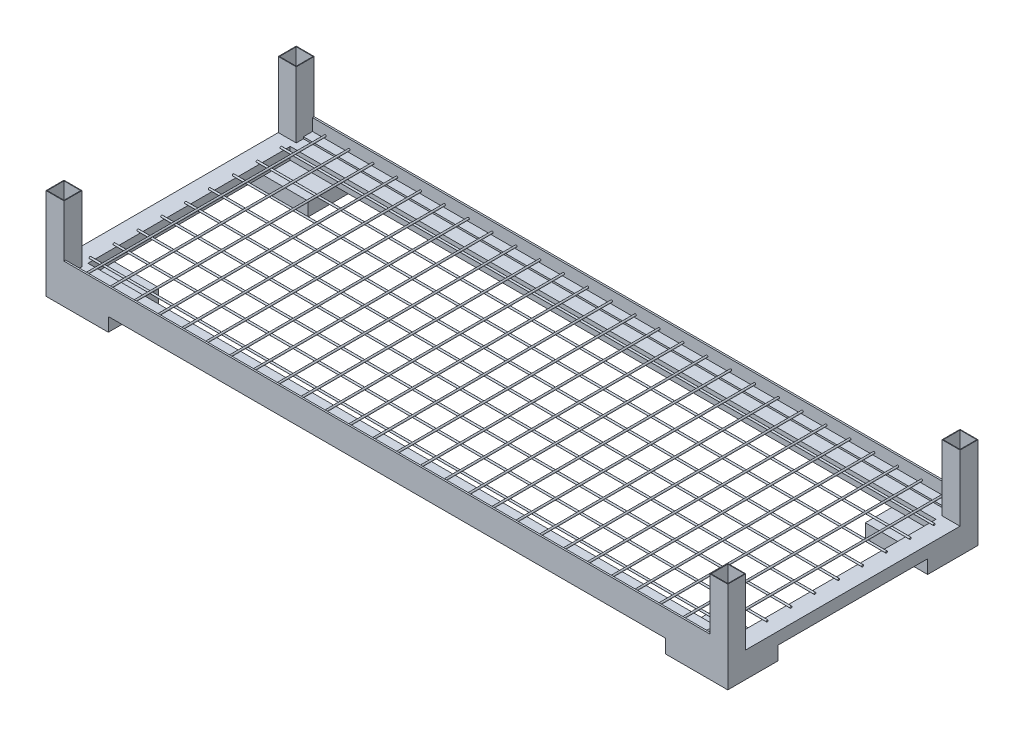
from build123d import *

# Parameters (mm, degrees)
SKETCH1_W             = 1444.625
SKETCH1_H             = 530.225
SKETCH1_W_2           = 1368.425
SKETCH1_H_2           = 428.625
BOSS_EXTRUDE1_DEPTH   = 25.4
SKETCH2_W             = 38.1
SKETCH2_H             = 38.1
SKETCH2_W_2           = 35.56
SKETCH2_H_2           = 35.56
BOSS_EXTRUDE2_DEPTH   = 139.7
SKETCH3_W             = 1368.425
SKETCH3_H             = 22.86
BOSS_EXTRUDE3_DEPTH   = 3.81
SKETCH4_R             = 1.905
BOSS_EXTRUDE4_DEPTH   = 1384.3
BOSS_EXTRUDE4_2_DEPTH = 1384.3
BOSS_EXTRUDE4_3_DEPTH = 1384.3
BOSS_EXTRUDE4_4_DEPTH = 1384.3
BOSS_EXTRUDE4_5_DEPTH = 1384.3
BOSS_EXTRUDE4_6_DEPTH = 1384.3
BOSS_EXTRUDE4_7_DEPTH = 1384.3
BOSS_EXTRUDE4_8_DEPTH = 1384.3
BOSS_EXTRUDE4_9_DEPTH = 1384.3
SKETCH5_W             = 1368.425
SKETCH5_H             = 3.556
BOSS_EXTRUDE5_DEPTH   = 25.4
SKETCH6_R             = 1.905
BOSS_EXTRUDE6_DEPTH   = 523.113
SKETCH7_W             = 132.08
SKETCH7_H             = 106.68
BOSS_EXTRUDE7_DEPTH   = 3.556
SKETCH8_W             = 132.08
SKETCH8_H             = 106.68
SKETCH8_W_2           = 124.968
SKETCH8_H_2           = 99.568
BOSS_EXTRUDE8_DEPTH   = 25.4
SKETCH9_W             = 35.56
SKETCH9_H             = 35.56
CUT_EXTRUDE1_DEPTH    = 22.606


with BuildPart() as part:
    # Sketch1 → Boss-Extrude1 (new body)
    with BuildSketch(Plane(origin=(0, 0, 0), x_dir=(1, 0, 0), z_dir=(0, 1, 0))):
        Rectangle(SKETCH1_W, SKETCH1_H)
        Rectangle(SKETCH1_W_2, SKETCH1_H_2, mode=Mode.SUBTRACT)
    extrude(amount=BOSS_EXTRUDE1_DEPTH)

    # Sketch2 → Boss-Extrude2 (add)
    with BuildSketch(Plane(origin=(0, 25.4, 0), x_dir=(1, 0, 0), z_dir=(0, 1, 0))):
        with Locations((-703.2625, 246.0625)):
            Rectangle(SKETCH2_W, SKETCH2_H)
        with Locations((-703.2625, 246.0625)):
            Rectangle(SKETCH2_W_2, SKETCH2_H_2, mode=Mode.SUBTRACT)
        with Locations((-703.2625, -246.0625)):
            Rectangle(SKETCH2_W, SKETCH2_H)
        with Locations((-703.2625, -246.0625)):
            Rectangle(SKETCH2_W_2, SKETCH2_H_2, mode=Mode.SUBTRACT)
        with Locations((703.2625, -246.0625)):
            Rectangle(SKETCH2_W, SKETCH2_H)
        with Locations((703.2625, -246.0625)):
            Rectangle(SKETCH2_W_2, SKETCH2_H_2, mode=Mode.SUBTRACT)
        with Locations((703.2625, 246.0625)):
            Rectangle(SKETCH2_W, SKETCH2_H)
        with Locations((703.2625, 246.0625)):
            Rectangle(SKETCH2_W_2, SKETCH2_H_2, mode=Mode.SUBTRACT)
    extrude(amount=BOSS_EXTRUDE2_DEPTH)

    # Sketch3 → Boss-Extrude3 (add)
    with BuildSketch(Plane(origin=(0, 25.4, 0), x_dir=(1, 0, 0), z_dir=(0, 1, 0))):
        with Locations((0, 253.6825)):
            Rectangle(SKETCH3_W, SKETCH3_H)
        with Locations((0, -253.6825)):
            Rectangle(SKETCH3_W, SKETCH3_H)
    extrude(amount=BOSS_EXTRUDE3_DEPTH)

    # Sketch5 → Boss-Extrude5 (add)
    with BuildSketch(Plane(origin=(0, 29.21, 0), x_dir=(1, 0, 0), z_dir=(0, 1, 0))):
        with Locations((0, -263.3345)):
            Rectangle(SKETCH5_W, SKETCH5_H)
        with Locations((0, 263.3345)):
            Rectangle(SKETCH5_W, SKETCH5_H)
    extrude(amount=BOSS_EXTRUDE5_DEPTH)

    # Sketch6 → Boss-Extrude6 (add)
    with BuildSketch(Plane(origin=(0, 0, 261.5565), x_dir=(-1, 0, 0), z_dir=(0, 0, -1))):
        with Locations((0, 34.925)):
            Circle(SKETCH6_R)
        with Locations((50.546, 34.925)):
            Circle(SKETCH6_R)
        with Locations((101.092, 34.925)):
            Circle(SKETCH6_R)
        with Locations((151.638, 34.925)):
            Circle(SKETCH6_R)
        with Locations((202.184, 34.925)):
            Circle(SKETCH6_R)
        with Locations((252.73, 34.925)):
            Circle(SKETCH6_R)
        with Locations((303.276, 34.925)):
            Circle(SKETCH6_R)
        with Locations((353.822, 34.925)):
            Circle(SKETCH6_R)
        with Locations((404.368, 34.925)):
            Circle(SKETCH6_R)
        with Locations((454.914, 34.925)):
            Circle(SKETCH6_R)
        with Locations((505.46, 34.925)):
            Circle(SKETCH6_R)
        with Locations((556.006, 34.925)):
            Circle(SKETCH6_R)
        with Locations((606.552, 34.925)):
            Circle(SKETCH6_R)
        with Locations((657.098, 34.925)):
            Circle(SKETCH6_R)
        with Locations((-50.546, 34.925)):
            Circle(SKETCH6_R)
        with Locations((-101.092, 34.925)):
            Circle(SKETCH6_R)
        with Locations((-151.638, 34.925)):
            Circle(SKETCH6_R)
        with Locations((-202.184, 34.925)):
            Circle(SKETCH6_R)
        with Locations((-252.73, 34.925)):
            Circle(SKETCH6_R)
        with Locations((-303.276, 34.925)):
            Circle(SKETCH6_R)
        with Locations((-353.822, 34.925)):
            Circle(SKETCH6_R)
        with Locations((-404.368, 34.925)):
            Circle(SKETCH6_R)
        with Locations((-454.914, 34.925)):
            Circle(SKETCH6_R)
        with Locations((-505.46, 34.925)):
            Circle(SKETCH6_R)
        with Locations((-556.006, 34.925)):
            Circle(SKETCH6_R)
        with Locations((-606.552, 34.925)):
            Circle(SKETCH6_R)
        with Locations((-657.098, 34.925)):
            Circle(SKETCH6_R)
    extrude(amount=BOSS_EXTRUDE6_DEPTH)

    # Sketch7 → Boss-Extrude7 (add)
    with BuildSketch(Plane.XZ):
        with Locations((-656.2725, -211.7725)):
            Rectangle(SKETCH7_W, SKETCH7_H)
        with Locations((-656.2725, 211.7725)):
            Rectangle(SKETCH7_W, SKETCH7_H)
        with Locations((656.2725, -211.7725)):
            Rectangle(SKETCH7_W, SKETCH7_H)
        with Locations((656.2725, 211.7725)):
            Rectangle(SKETCH7_W, SKETCH7_H)
    extrude(amount=BOSS_EXTRUDE7_DEPTH)

    # Sketch8 → Boss-Extrude8 (add)
    with BuildSketch(Plane.XZ.offset(3.556)):
        with Locations((-656.2725, -211.7725)):
            Rectangle(SKETCH8_W, SKETCH8_H)
        with Locations((-656.2725, -211.7725)):
            Rectangle(SKETCH8_W_2, SKETCH8_H_2, mode=Mode.SUBTRACT)
        with Locations((-656.2725, 211.7725)):
            Rectangle(SKETCH8_W, SKETCH8_H)
        with Locations((-656.2725, 211.7725)):
            Rectangle(SKETCH8_W_2, SKETCH8_H_2, mode=Mode.SUBTRACT)
        with Locations((656.2725, 211.7725)):
            Rectangle(SKETCH8_W, SKETCH8_H)
        with Locations((656.2725, 211.7725)):
            Rectangle(SKETCH8_W_2, SKETCH8_H_2, mode=Mode.SUBTRACT)
        with Locations((656.2725, -211.7725)):
            Rectangle(SKETCH8_W, SKETCH8_H)
        with Locations((656.2725, -211.7725)):
            Rectangle(SKETCH8_W_2, SKETCH8_H_2, mode=Mode.SUBTRACT)
    extrude(amount=BOSS_EXTRUDE8_DEPTH)

    # Sketch9 → Cut-Extrude1 (cut)
    with BuildSketch(Plane(origin=(0, 25.4, 0), x_dir=(1, 0, 0), z_dir=(0, 1, 0))):
        with Locations((-703.2625, 246.0625)):
            Rectangle(SKETCH9_W, SKETCH9_H)
        with Locations((-703.2625, -246.0625)):
            Rectangle(SKETCH9_W, SKETCH9_H)
        with Locations((703.2625, -246.0625)):
            Rectangle(SKETCH9_W, SKETCH9_H)
        with Locations((703.2625, 246.0625)):
            Rectangle(SKETCH9_W, SKETCH9_H)
    extrude(amount=-CUT_EXTRUDE1_DEPTH, mode=Mode.SUBTRACT)


with BuildPart() as body_2:
    # Sketch4 → Boss-Extrude4 (new body)
    with BuildSketch(Plane(origin=(-690.5625, 0, 0), x_dir=(0, 0, -1), z_dir=(1, 0, 0))):
        with Locations((-1.318131718, 27.305)):
            Circle(SKETCH4_R)
    extrude(amount=BOSS_EXTRUDE4_DEPTH)


with BuildPart() as body_3:
    # Sketch4 → Boss-Extrude4 2 (new body)
    with BuildSketch(Plane(origin=(-690.5625, 0, 0), x_dir=(0, 0, -1), z_dir=(1, 0, 0))):
        with Locations((49.227868282, 27.305)):
            Circle(SKETCH4_R)
    extrude(amount=BOSS_EXTRUDE4_2_DEPTH)


with BuildPart() as body_4:
    # Sketch4 → Boss-Extrude4 3 (new body)
    with BuildSketch(Plane(origin=(-690.5625, 0, 0), x_dir=(0, 0, -1), z_dir=(1, 0, 0))):
        with Locations((99.773868282, 27.305)):
            Circle(SKETCH4_R)
    extrude(amount=BOSS_EXTRUDE4_3_DEPTH)


with BuildPart() as body_5:
    # Sketch4 → Boss-Extrude4 4 (new body)
    with BuildSketch(Plane(origin=(-690.5625, 0, 0), x_dir=(0, 0, -1), z_dir=(1, 0, 0))):
        with Locations((150.319868282, 27.305)):
            Circle(SKETCH4_R)
    extrude(amount=BOSS_EXTRUDE4_4_DEPTH)


with BuildPart() as body_6:
    # Sketch4 → Boss-Extrude4 5 (new body)
    with BuildSketch(Plane(origin=(-690.5625, 0, 0), x_dir=(0, 0, -1), z_dir=(1, 0, 0))):
        with Locations((200.865868282, 27.305)):
            Circle(SKETCH4_R)
    extrude(amount=BOSS_EXTRUDE4_5_DEPTH)


with BuildPart() as body_7:
    # Sketch4 → Boss-Extrude4 6 (new body)
    with BuildSketch(Plane(origin=(-690.5625, 0, 0), x_dir=(0, 0, -1), z_dir=(1, 0, 0))):
        with Locations((-51.864131718, 27.305)):
            Circle(SKETCH4_R)
    extrude(amount=BOSS_EXTRUDE4_6_DEPTH)


with BuildPart() as body_8:
    # Sketch4 → Boss-Extrude4 7 (new body)
    with BuildSketch(Plane(origin=(-690.5625, 0, 0), x_dir=(0, 0, -1), z_dir=(1, 0, 0))):
        with Locations((-102.410131718, 27.305)):
            Circle(SKETCH4_R)
    extrude(amount=BOSS_EXTRUDE4_7_DEPTH)


with BuildPart() as body_9:
    # Sketch4 → Boss-Extrude4 8 (new body)
    with BuildSketch(Plane(origin=(-690.5625, 0, 0), x_dir=(0, 0, -1), z_dir=(1, 0, 0))):
        with Locations((-152.956131718, 27.305)):
            Circle(SKETCH4_R)
    extrude(amount=BOSS_EXTRUDE4_8_DEPTH)


with BuildPart() as body_10:
    # Sketch4 → Boss-Extrude4 9 (new body)
    with BuildSketch(Plane(origin=(-690.5625, 0, 0), x_dir=(0, 0, -1), z_dir=(1, 0, 0))):
        with Locations((-203.502131718, 27.305)):
            Circle(SKETCH4_R)
    extrude(amount=BOSS_EXTRUDE4_9_DEPTH)


solid = Compound([part.part, body_2.part, body_3.part, body_4.part, body_5.part, body_6.part, body_7.part, body_8.part, body_9.part, body_10.part])
